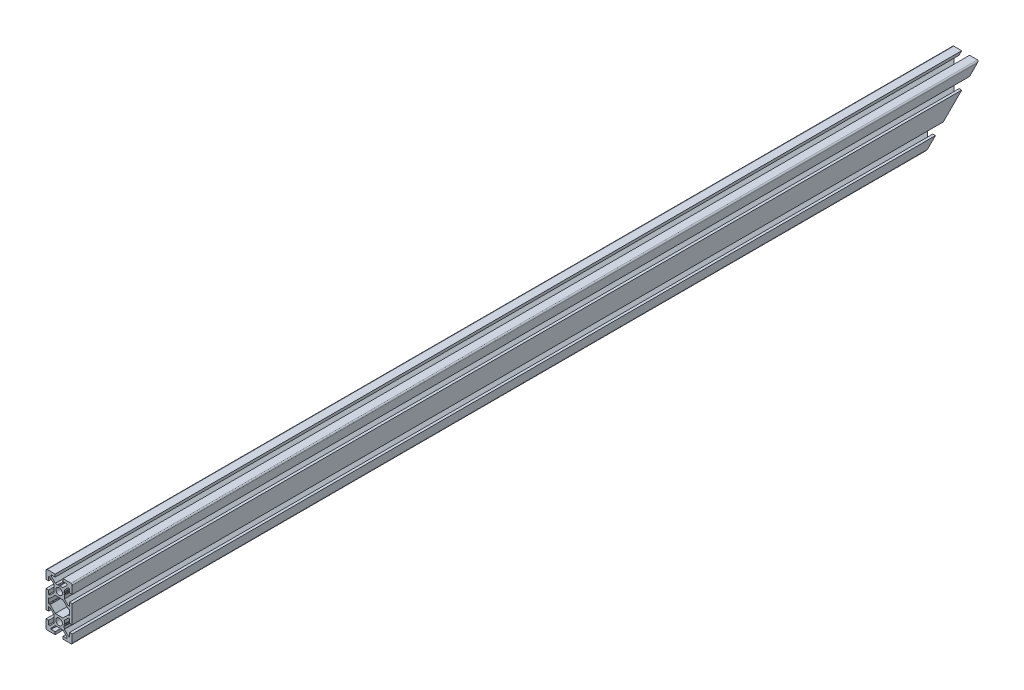
from build123d import *

# Parameters (mm, degrees)
SKETCH1_R           = 2.5
BOSS_EXTRUDE1_DEPTH = 345.5
CUT_EXTRUDE2_DEPTH  = 21
SKETCH4_R           = 2
CUT_EXTRUDE3_DEPTH  = 21


with BuildPart() as part:
    # Sketch1 → Boss-Extrude1 (new body, symmetric)
    with BuildSketch(Plane(origin=(0, 0, -600), x_dir=(-1, 0, 0), z_dir=(0, 0, -1))):
        with BuildLine():
            Line((10, -7), (10, 7))
            Line((10, 7), (8, 7))
            Line((8, 7), (8, 4))
            Line((8, 4), (7.060660172, 4))
            Line((7.060660172, 4), (4, 7.060660172))
            Line((4, 7.060660172), (4, 7.5))
            Line((4, 7.5), (3.750976592, 8.781114371))
            Line((3.750976592, 8.781114371), (3.933012702, 9.096410162))
            ThreePointArc((3.933012702, 9.096410162), (4, 9.346410162), (3.933012702, 9.596410162))
            Line((3.933012702, 9.596410162), (3.7, 10))
            Line((3.7, 10), (3.933012702, 10.403589838))
            ThreePointArc((3.933012702, 10.403589838), (3.982962913, 10.524180316), (4, 10.653589838))
            Line((4, 10.653589838), (4, 12.939339828))
            Line((4, 12.939339828), (7.060660172, 16))
            Line((7.060660172, 16), (8, 16))
            Line((8, 16), (8, 13))
            Line((8, 13), (10, 13))
            Line((10, 13), (10, 19))
            ThreePointArc((10, 19), (9.707106781, 19.707106781), (9, 20))
            Line((9, 20), (3, 20))
            Line((3, 20), (3, 18))
            Line((3, 18), (6, 18))
            Line((6, 18), (6, 17.060660172))
            Line((6, 17.060660172), (2.939339828, 14))
            Line((2.939339828, 14), (2.5, 14))
            Line((2.5, 14), (1.218885629, 13.750976592))
            Line((1.218885629, 13.750976592), (0.903589838, 13.933012702))
            ThreePointArc((0.903589838, 13.933012702), (0.653589838, 14), (0.403589838, 13.933012702))
            Line((0.403589838, 13.933012702), (0, 13.7))
            Line((0, 13.7), (-0.403589838, 13.933012702))
            ThreePointArc((-0.403589838, 13.933012702), (-0.524180316, 13.982962913), (-0.653589838, 14))
            Line((-0.653589838, 14), (-2.939339828, 14))
            Line((-2.939339828, 14), (-6, 17.060660172))
            Line((-6, 17.060660172), (-6, 18))
            Line((-6, 18), (-3, 18))
            Line((-3, 18), (-3, 20))
            Line((-3, 20), (-9, 20))
            ThreePointArc((-9, 20), (-9.707106781, 19.707106781), (-10, 19))
            Line((-10, 19), (-10, 13))
            Line((-10, 13), (-8, 13))
            Line((-8, 13), (-8, 16))
            Line((-8, 16), (-7.060660172, 16))
            Line((-7.060660172, 16), (-4, 12.939339828))
            Line((-4, 12.939339828), (-4, 12.5))
            Line((-4, 12.5), (-3.750976592, 11.218885629))
            Line((-3.750976592, 11.218885629), (-3.933012702, 10.903589838))
            ThreePointArc((-3.933012702, 10.903589838), (-4, 10.653589838), (-3.933012702, 10.403589838))
            Line((-3.933012702, 10.403589838), (-3.7, 10))
            Line((-3.7, 10), (-3.933012702, 9.596410162))
            ThreePointArc((-3.933012702, 9.596410162), (-3.982962913, 9.475819684), (-4, 9.346410162))
            Line((-4, 9.346410162), (-4, 7.060660172))
            Line((-4, 7.060660172), (-7.060660172, 4))
            Line((-7.060660172, 4), (-8, 4))
            Line((-8, 4), (-8, 7))
            Line((-8, 7), (-10, 7))
            Line((-10, 7), (-10, -7))
            Line((-10, -7), (-8, -7))
            Line((-8, -7), (-8, -4))
            Line((-8, -4), (-7.060660172, -4))
            Line((-7.060660172, -4), (-4, -7.060660172))
            Line((-4, -7.060660172), (-4, -9.346410162))
            ThreePointArc((-4, -9.346410162), (-3.982962913, -9.475819684), (-3.933012702, -9.596410162))
            Line((-3.933012702, -9.596410162), (-3.7, -10))
            Line((-3.7, -10), (-3.933012702, -10.403589838))
            ThreePointArc((-3.933012702, -10.403589838), (-4, -10.653589838), (-3.933012702, -10.903589838))
            Line((-3.933012702, -10.903589838), (-3.750976592, -11.218885629))
            Line((-3.750976592, -11.218885629), (-4, -12.5))
            Line((-4, -12.5), (-4, -12.939339828))
            Line((-4, -12.939339828), (-7.060660172, -16))
            Line((-7.060660172, -16), (-8, -16))
            Line((-8, -16), (-8, -13))
            Line((-8, -13), (-10, -13))
            Line((-10, -13), (-10, -19))
            ThreePointArc((-10, -19), (-9.707106781, -19.707106781), (-9, -20))
            Line((-9, -20), (-3, -20))
            Line((-3, -20), (-3, -18))
            Line((-3, -18), (-6, -18))
            Line((-6, -18), (-6, -17.060660172))
            Line((-6, -17.060660172), (-2.939339828, -14))
            Line((-2.939339828, -14), (-0.653589838, -14))
            ThreePointArc((-0.653589838, -14), (-0.524180316, -13.982962913), (-0.403589838, -13.933012702))
            Line((-0.403589838, -13.933012702), (0, -13.7))
            Line((0, -13.7), (0.403589839, -13.933012702))
            ThreePointArc((0.403589839, -13.933012702), (0.653589839, -14), (0.903589838, -13.933012702))
            Line((0.903589838, -13.933012702), (1.218885629, -13.750976592))
            Line((1.218885629, -13.750976592), (2.5, -14))
            Line((2.5, -14), (2.939339828, -14))
            Line((2.939339828, -14), (6, -17.060660172))
            Line((6, -17.060660172), (6, -18))
            Line((6, -18), (3, -18))
            Line((3, -18), (3, -20))
            Line((3, -20), (9, -20))
            ThreePointArc((9, -20), (9.707106781, -19.707106781), (10, -19))
            Line((10, -19), (10, -13))
            Line((10, -13), (8, -13))
            Line((8, -13), (8, -16))
            Line((8, -16), (7.060660172, -16))
            Line((7.060660172, -16), (4, -12.939339828))
            Line((4, -12.939339828), (4, -10.653589838))
            ThreePointArc((4, -10.653589838), (3.982962913, -10.524180316), (3.933012702, -10.403589838))
            Line((3.933012702, -10.403589838), (3.7, -10))
            Line((3.7, -10), (3.933012702, -9.596410162))
            ThreePointArc((3.933012702, -9.596410162), (4, -9.346410162), (3.933012702, -9.096410162))
            Line((3.933012702, -9.096410162), (3.750976592, -8.781114371))
            Line((3.750976592, -8.781114371), (4, -7.5))
            Line((4, -7.5), (4, -7.060660172))
            Line((4, -7.060660172), (7.060660172, -4))
            Line((7.060660172, -4), (8, -4))
            Line((8, -4), (8, -7))
            Line((8, -7), (10, -7))
        make_face()
        with Locations((0, -10)):
            Circle(SKETCH1_R, mode=Mode.SUBTRACT)
        with Locations((0, 10)):
            Circle(SKETCH1_R, mode=Mode.SUBTRACT)
        with BuildLine():
            Line((8, 1.7), (8, -1.7))
            ThreePointArc((8, -1.7), (7.912132034, -1.912132034), (7.7, -2))
            Line((7.7, -2), (7.063603897, -2))
            ThreePointArc((7.063603897, -2), (6.948798867, -2.02283614), (6.851471863, -2.087867966))
            Line((6.851471863, -2.087867966), (2.939339828, -6))
            Line((2.939339828, -6), (-2.939339828, -6))
            Line((-2.939339828, -6), (-6.851471863, -2.087867966))
            ThreePointArc((-6.851471863, -2.087867966), (-6.948798867, -2.02283614), (-7.063603897, -2))
            Line((-7.063603897, -2), (-7.7, -2))
            ThreePointArc((-7.7, -2), (-7.912132034, -1.912132034), (-8, -1.7))
            Line((-8, -1.7), (-8, 1.7))
            ThreePointArc((-8, 1.7), (-7.912132034, 1.912132034), (-7.7, 2))
            Line((-7.7, 2), (-7.063603897, 2))
            ThreePointArc((-7.063603897, 2), (-6.948798867, 2.02283614), (-6.851471863, 2.087867966))
            Line((-6.851471863, 2.087867966), (-2.939339828, 6))
            Line((-2.939339828, 6), (2.939339828, 6))
            Line((2.939339828, 6), (6.851471863, 2.087867966))
            ThreePointArc((6.851471863, 2.087867966), (6.948798867, 2.02283614), (7.063603897, 2))
            Line((7.063603897, 2), (7.7, 2))
            ThreePointArc((7.7, 2), (7.912132034, 1.912132034), (8, 1.7))
        make_face(mode=Mode.SUBTRACT)
    extrude(amount=BOSS_EXTRUDE1_DEPTH, both=True)

    # Sketch3 → Cut-Extrude2 (cut, through all)
    with BuildSketch(Plane.ZY.offset(10)):
        Polygon((-945.5, 20), (-905.5, -20), (-945.5, -20), align=None)
    extrude(amount=-CUT_EXTRUDE2_DEPTH, mode=Mode.SUBTRACT)

    # Sketch4 → Cut-Extrude3 (cut, through all)
    with BuildSketch(Plane.ZY.offset(10)):
        with Locations((-264.5, 10)):
            Circle(SKETCH4_R)
        with Locations((-264.5, -10)):
            Circle(SKETCH4_R)
    extrude(amount=-CUT_EXTRUDE3_DEPTH, mode=Mode.SUBTRACT)


solid = part.part
